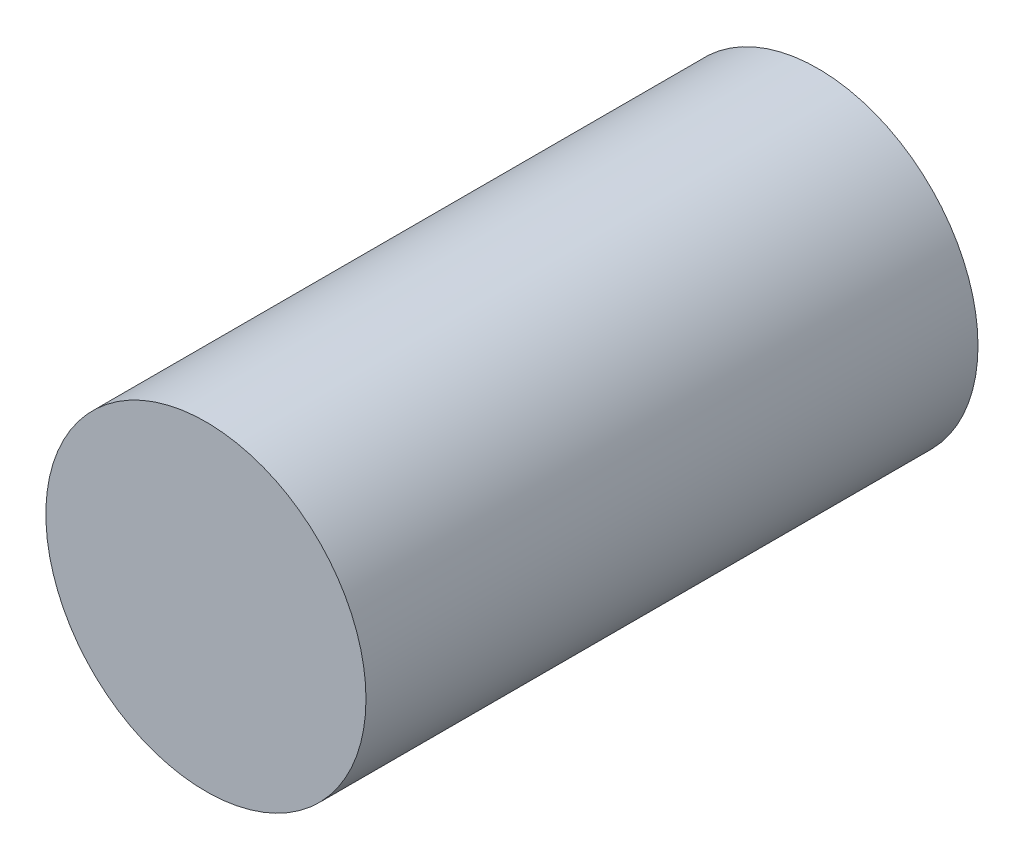
from build123d import *

# Parameters (mm, degrees)
SKETCH1_R           = 17
BOSS_EXTRUDE1_DEPTH = 65


with BuildPart() as part:
    # Sketch1 → Boss-Extrude1 (new body)
    with BuildSketch(Plane.XY):
        Circle(SKETCH1_R)
    extrude(amount=BOSS_EXTRUDE1_DEPTH)


solid = part.part
